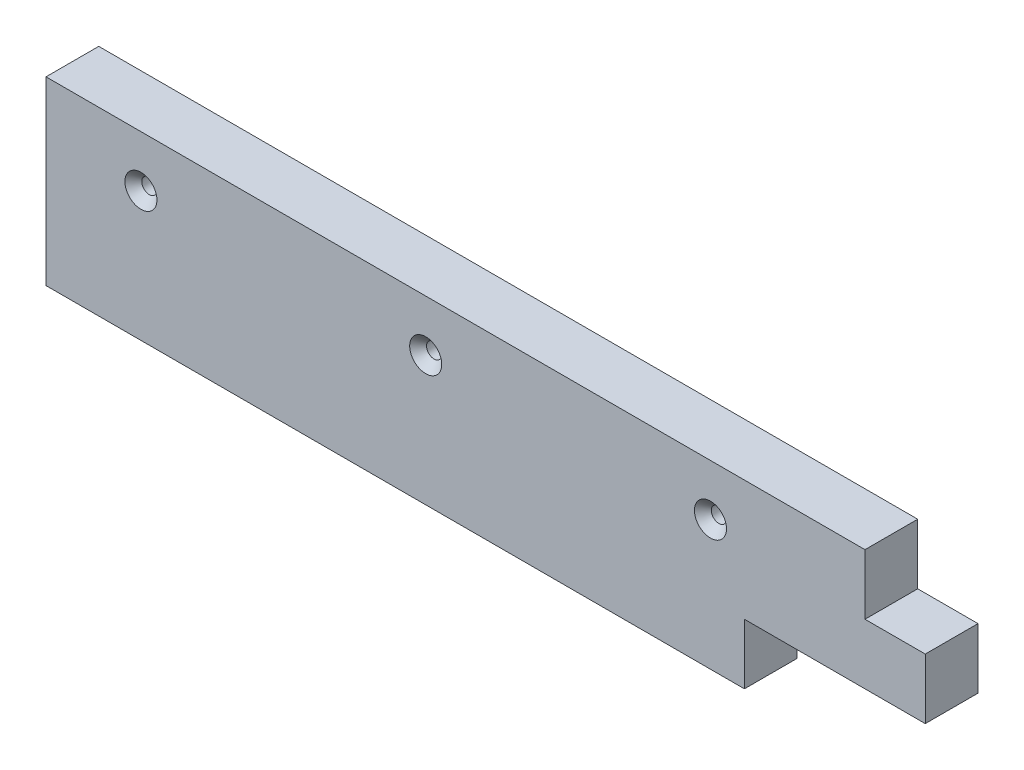
from build123d import *

# Parameters (mm, degrees)
SKETCH1_W                                            = 370.50412818
SKETCH1_H                                            = 22.225
BOSS_EXTRUDE1_DEPTH                                  = 38.1
CSK_FOR_M6_HEX_SOCKET_COUNTERSUNK_HEAD_S_D           = 6.4
CSK_FOR_M6_HEX_SOCKET_COUNTERSUNK_HEAD_S_CSINK_D     = 13.5
CSK_FOR_M6_HEX_SOCKET_COUNTERSUNK_HEAD_S_CSINK_ANGLE = 90
SKETCH3_W                                            = 25.4
SKETCH3_H                                            = 25.4
SKETCH3_W_2                                          = 76.2
CUT_EXTRUDE1_DEPTH                                   = 23.225


with BuildPart() as part:
    # Sketch1 → Boss-Extrude1 (new body, symmetric)
    with BuildSketch(Plane(origin=(0, 0, 0), x_dir=(1, 0, 0), z_dir=(0, 1, 0))):
        Rectangle(SKETCH1_W, SKETCH1_H)
    extrude(amount=BOSS_EXTRUDE1_DEPTH, both=True)

    # CSK for M6 Hex Socket Countersunk Head Screw6 (through all)
    with Locations(Plane.XY.offset(11.1125)):
        with Locations((-145.252063961, 16.50746), (-25.252063961, 16.50746), (94.747936039, 16.50746)):
            CounterSinkHole(CSK_FOR_M6_HEX_SOCKET_COUNTERSUNK_HEAD_S_D / 2, CSK_FOR_M6_HEX_SOCKET_COUNTERSUNK_HEAD_S_CSINK_D / 2, counter_sink_angle=CSK_FOR_M6_HEX_SOCKET_COUNTERSUNK_HEAD_S_CSINK_ANGLE)

    # Sketch3 → Cut-Extrude1 (cut, through all)
    with BuildSketch(Plane.XY.offset(11.1125)):
        with Locations((172.55206409, 25.4)):
            Rectangle(SKETCH3_W, SKETCH3_H)
        with Locations((147.15206409, -25.4)):
            Rectangle(SKETCH3_W_2, SKETCH3_H)
    extrude(amount=-CUT_EXTRUDE1_DEPTH, mode=Mode.SUBTRACT)


solid = part.part
